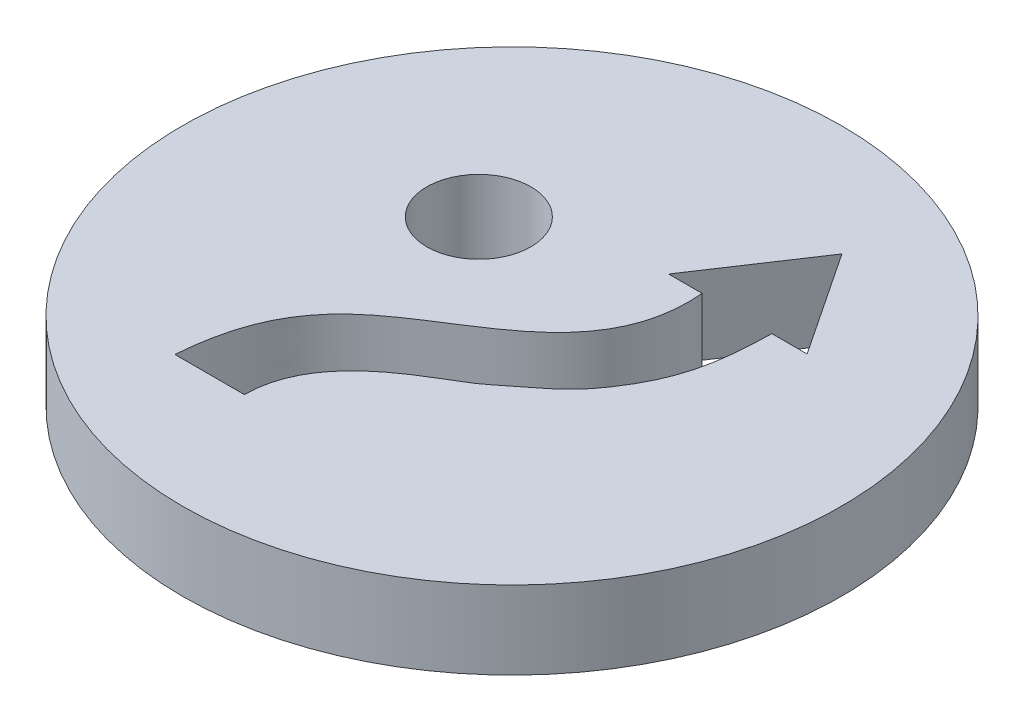
from build123d import *

# Parameters (mm, degrees)
SKETCH1_R           = 9.5
SKETCH1_R_2         = 1.5
BOSS_EXTRUDE1_DEPTH = 2.25


with BuildPart() as part:
    # Sketch1 → Boss-Extrude1 (new body)
    with BuildSketch(Plane(origin=(0, 0, 0), x_dir=(1, 0, 0), z_dir=(0, 1, 0))):
        Circle(SKETCH1_R)
        with Locations((-2.952501305, 1.996568505)):
            Circle(SKETCH1_R_2, mode=Mode.SUBTRACT)
        with BuildLine():
            Line((1.210041518, 3.303413345), (2.178074733, 3.303413345))
            add(Edge.make_bspline(
                [(2.178074733, 3.303413345), (2.444856065, 0.149541279), (-2.085629529, -1.114991667), (-3.758110102, -3.954281272), (-3.896333689, -5.820299703)],
                knots=[0, 0, 0, 0, 0.63008416, 1, 1, 1, 1], degree=3))
            Line((-3.896333689, -5.820299703), (-1.896333689, -5.820299703))
            add(Edge.make_bspline(
                [(4.186743653, 3.303413345), (4.162331661, 1.716633845), (3.916646292, 0.656016278), (2.663767731, -1.102040856), (1.822435365, -1.678254748), (0.735292504, -2.593233031), (-1.88135337, -3.72928874), (-1.896333689, -5.820299703)],
                knots=[0, 0, 0, 0, 0.433164655, 0.505148227, 0.695981554, 0.747852148, 1, 1, 1, 1], degree=3))
            Line((4.186743653, 3.303413345), (5.203178529, 3.303413345))
            Line((5.203178529, 3.303413345), (3.206610024, 6.304316311))
            Line((3.206610024, 6.304316311), (1.210041518, 3.303413345))
        make_face(mode=Mode.SUBTRACT)
    extrude(amount=BOSS_EXTRUDE1_DEPTH)


solid = part.part
